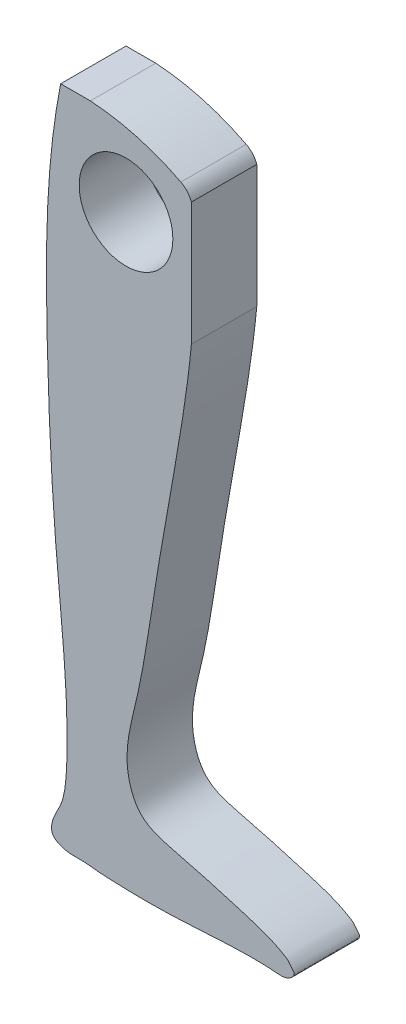
from build123d import *

# Parameters (mm, degrees)
SKETCH1_R           = 2.15
BOSS_EXTRUDE1_DEPTH = 3


with BuildPart() as part:
    # Sketch1 → Boss-Extrude1 (new body)
    with BuildSketch(Plane.XY):
        with BuildLine():
            Line((1.363992025, 0), (0, 0))
            add(Edge.make_bspline(
                [(0, 0), (-0.691116011, -3.473098711), (-0.707043287, -9.797190132), (-0.307408847, -18.656108718), (0.387493558, -24.294835561), (0.254434787, -27.558254823), (0.121404256, -28.579616794), (-0.379389945, -29.308813555), (-0.471578307, -30.026160798), (0.242046392, -30.463978682), (0.931480691, -30.34716901), (1.632131305, -30.45033705), (2.820970781, -30.515283358), (5.355366824, -30.570821341), (7.914792554, -30.29241965), (9.816178061, -30.361628802), (10.374761597, -30.443880051), (10.803130979, -30.051595114), (10.578450403, -29.809469239), (10.458098423, -29.630517953), (9.742039725, -29.175159347), (8.222428565, -28.701442762), (6.817267531, -28.291476351), (6, -28.078862268)],
                knots=[0, 0, 0, 0, 0.140411162, 0.250881911, 0.354065852, 0.364890775, 0.381699906, 0.393575399, 0.400647103, 0.406820295, 0.423093677, 0.427756196, 0.434983009, 0.470514087, 0.528627146, 0.537310011, 0.546082433, 0.551291914, 0.553920331, 0.55766009, 0.560135786, 0.587167249, 0.620268724, 0.620268724, 0.620268724, 0.620268724], degree=3))
            add(Edge.make_bspline(
                [(6, -28.078862268), (5.804863943, -28.028097161), (4.991402705, -27.822209808), (3.63493925, -27.520529272), (2.774123079, -25.336860351), (3.675524649, -22.320868331), (4.258616639, -18.094455988), (5.189224613, -12.960759876), (5.812313799, -9.324888102), (6, -7.354681079)],
                knots=[0.620268724, 0.620268724, 0.620268724, 0.620268724, 0.628172245, 0.652800075, 0.671011982, 0.71358182, 0.774572908, 0.842137069, 0.921181085, 0.921181085, 0.921181085, 0.921181085], degree=3))
            Line((6, -7.354681079), (6, -1.701801846))
            ThreePointArc((6, -1.701801846), (5.810634706, -1.37968086), (5.516244982, -1.14955951))
            ThreePointArc((5.516244982, -1.14955951), (3.499372708, -0.360751301), (1.363992025, 0))
        make_face()
        with Locations((3, -3.6)):
            Circle(SKETCH1_R, mode=Mode.SUBTRACT)
    extrude(amount=BOSS_EXTRUDE1_DEPTH)


solid = part.part
